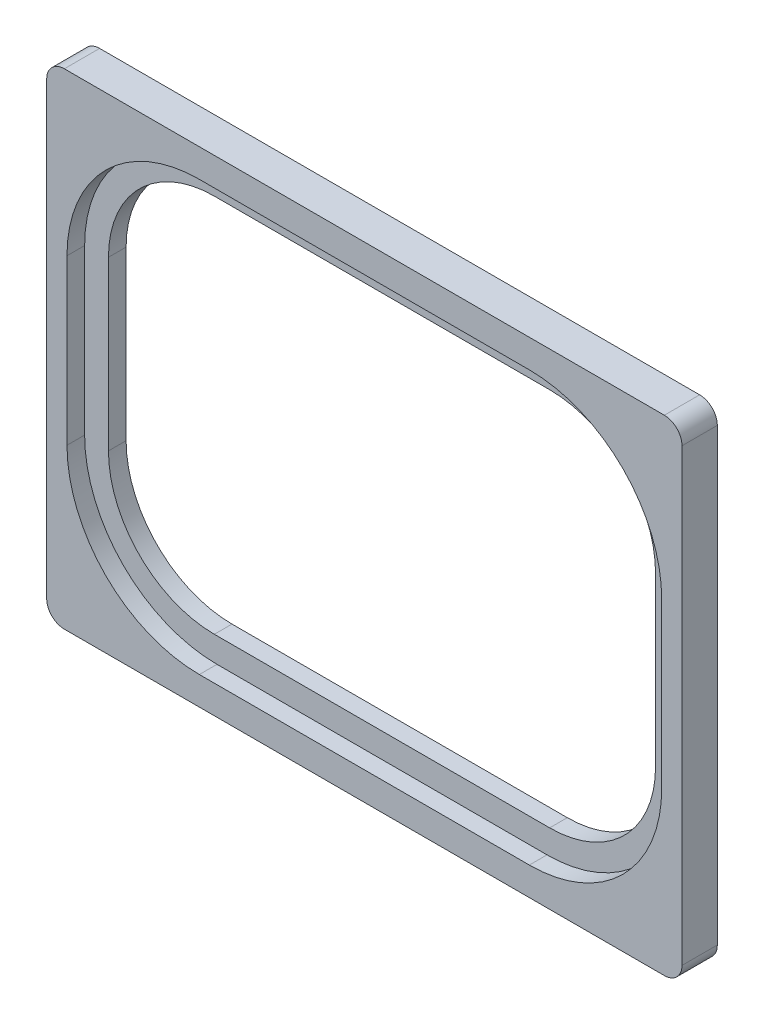
from build123d import *

# Parameters (mm, degrees)
SKETCH_1_W          = 72
SKETCH_1_H          = 55
EXTRUDE_1_DEPTH     = 4
FILLET_1_R          = 2
CUT_EXTRUDE_1_REACH = 6
CUT_EXTRUDE_2_DEPTH = 2


with BuildPart() as part:
    # 草图1 → 凸台-拉伸1 (new body)
    with BuildSketch(Plane.XY):
        Rectangle(SKETCH_1_W, SKETCH_1_H)
    extrude(amount=EXTRUDE_1_DEPTH)

    # 圆角1
    fillet_1_edges = [part.edges().sort_by_distance(p)[0] for p in [
        (-36, 27.5, 2),
        (36, 27.5, 2),
        (36, -27.5, 2),
        (-36, -27.5, 2),
    ]]
    fillet(fillet_1_edges, radius=FILLET_1_R)

    # 草图2 → 切除-拉伸1 (cut, up to next)
    with BuildSketch(Plane.XY.offset(4), mode=Mode.PRIVATE) as cut_extrude_1_sk1:
        with BuildLine():
            Line((-31, 9.5), (-31, -9.5))
            ThreePointArc((-31, -9.5), (-27.485281374, -17.985281374), (-19, -21.5))
            Line((-19, -21.5), (19, -21.5))
            ThreePointArc((19, -21.5), (27.485281374, -17.985281374), (31, -9.5))
            Line((31, -9.5), (31, 9.5))
            ThreePointArc((31, 9.5), (27.485281374, 17.985281374), (19, 21.5))
            Line((19, 21.5), (-19, 21.5))
            ThreePointArc((-19, 21.5), (-27.485281374, 17.985281374), (-31, 9.5))
        make_face()
    cut_extrude_1_tool1 = extrude(cut_extrude_1_sk1.sketch, amount=-CUT_EXTRUDE_1_REACH, mode=Mode.PRIVATE) & part.part
    add(cut_extrude_1_tool1.solids().sort_by_distance((0, 0, 4))[0], mode=Mode.SUBTRACT)

    # 草图3 → 切除-拉伸2 (cut)
    with BuildSketch(Plane.XY.offset(4)):
        with BuildLine():
            Line((18.7, 24.3), (-18.7, 24.3))
            ThreePointArc((-18.7, 24.3), (-29.306601718, 19.906601718), (-33.7, 9.3))
            Line((-33.7, 9.3), (-33.7, -9.3))
            ThreePointArc((-33.7, -9.3), (-29.306601718, -19.906601718), (-18.7, -24.3))
            Line((-18.7, -24.3), (18.7, -24.3))
            ThreePointArc((18.7, -24.3), (29.306601718, -19.906601718), (33.7, -9.3))
            Line((33.7, -9.3), (33.7, 9.3))
            ThreePointArc((33.7, 9.3), (29.306601718, 19.906601718), (18.7, 24.3))
        make_face()
    extrude(amount=-CUT_EXTRUDE_2_DEPTH, mode=Mode.SUBTRACT)


solid = part.part
